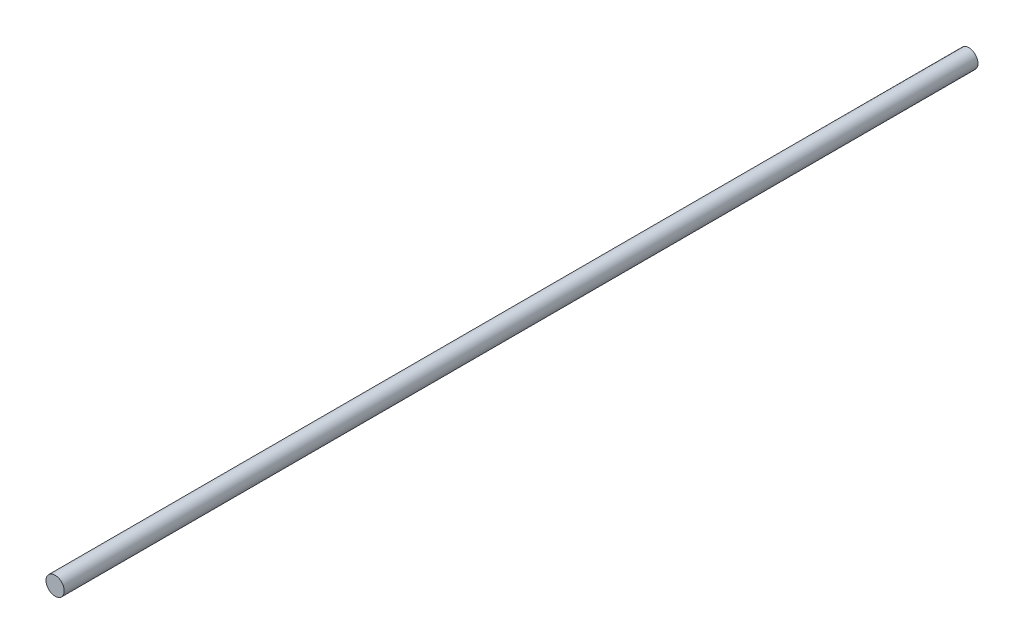
from build123d import *

# Parameters (mm, degrees)
ESQUISSE1_R        = 4
BOSS_EXTRU_1_DEPTH = 400


with BuildPart() as part:
    # Esquisse1 → Boss.-Extru.1 (new body)
    with BuildSketch(Plane.XY):
        Circle(ESQUISSE1_R)
    extrude(amount=BOSS_EXTRU_1_DEPTH)


solid = part.part
